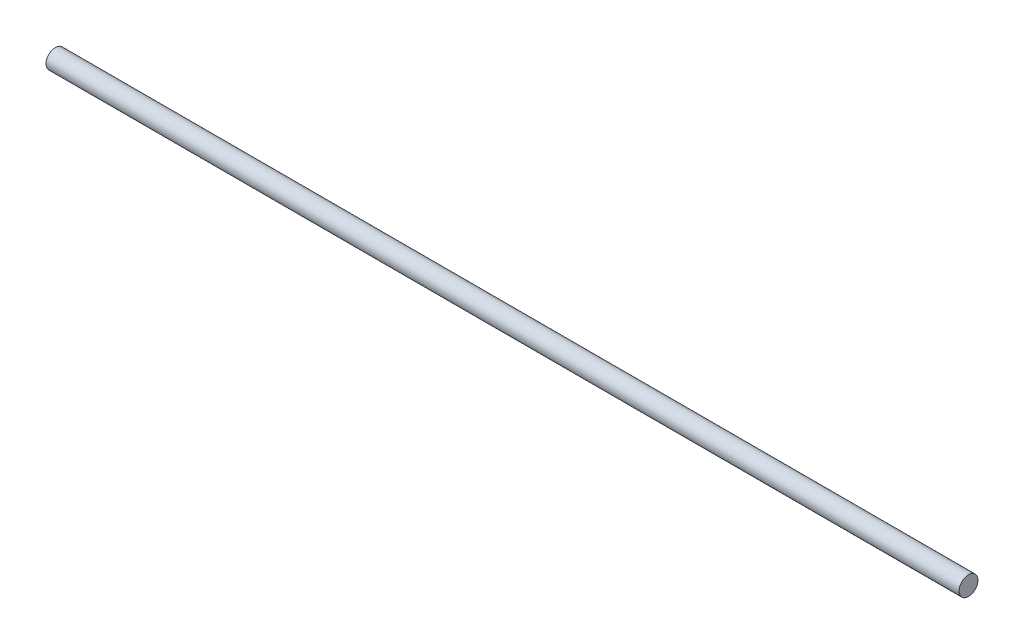
from build123d import *

# Parameters (mm, degrees)
SKETCH1_R           = 2.5
BOSS_EXTRUDE1_DEPTH = 120.65


with BuildPart() as part:
    # Sketch1 → Boss-Extrude1 (new, symmetric)
    with BuildSketch(Plane(origin=(0, 0, 0), x_dir=(0, 0, -1), z_dir=(1, 0, 0))):
        Circle(SKETCH1_R)
    extrude(amount=BOSS_EXTRUDE1_DEPTH, both=True)


solid = part.part
